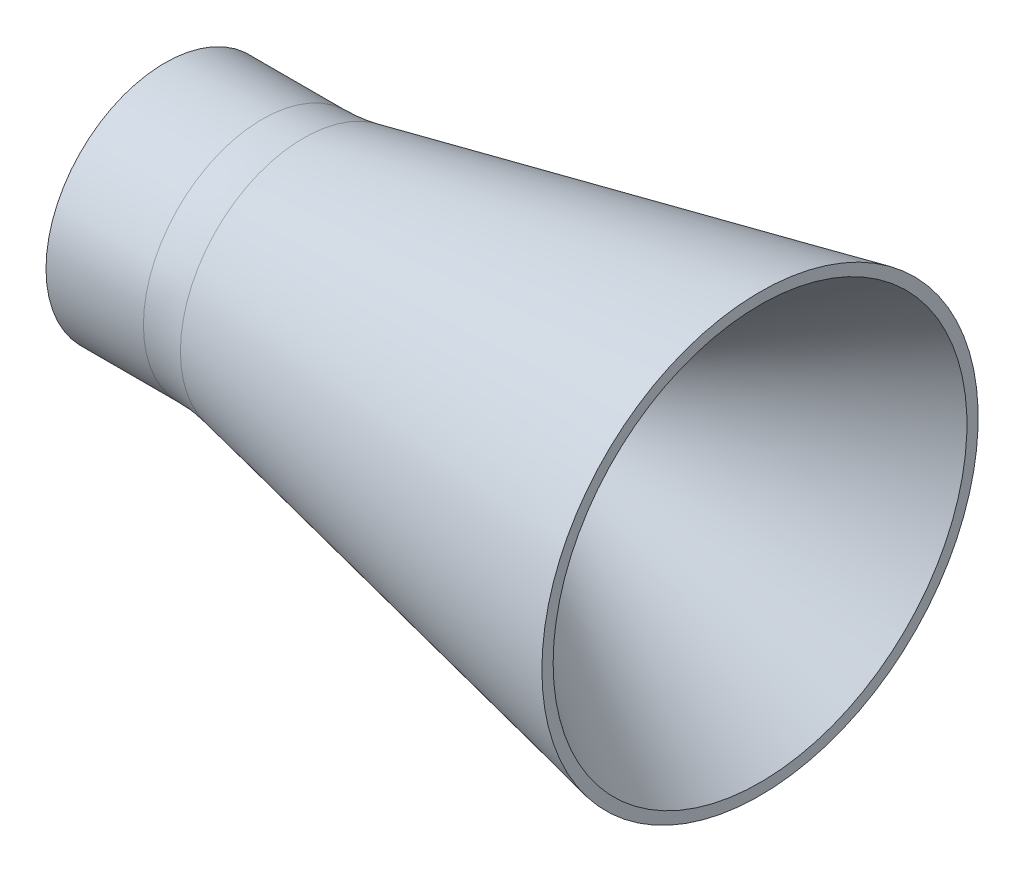
from build123d import *


with BuildPart() as part:
    # Sketch1 → Revolve2 (revolve)
    with BuildSketch(Plane.XY):
        with BuildLine():
            Line((45.639160326, 28.298601183), (95.74633283, 9.064259762))
            ThreePointArc((95.74633283, 9.064259762), (102.791629792, 7.077280519), (110.081050812, 6.407476822))
            Line((110.081050812, 6.407476822), (127.851823553, 6.407476822))
            ThreePointArc((127.851823553, 6.407476822), (139.546691742, 8.155286583), (150.219539692, 13.24597392))
            Line((150.219539692, 13.24597392), (246.802204076, 78.391803626))
            Line((246.802204076, 78.391803626), (246.802204076, 83.391803626))
            Line((246.802204076, 83.391803626), (43.876590917, 41.163939374))
            ThreePointArc((43.876590917, 41.163939374), (34.757151884, 39.749500606), (25.540810641, 39.276362798))
            Line((25.540810641, 39.276362798), (-17.770606993, 39.276362798))
            Line((-17.770606993, 39.276362798), (-17.770606993, 34.276362798))
            Line((-17.770606993, 34.276362798), (13.386044867, 34.276362798))
            ThreePointArc((13.386044867, 34.276362798), (29.787242162, 32.769304479), (45.639160326, 28.298601183))
        make_face()
    revolve(axis=Axis((-9.079018431, -13.592523178, 0), (1, 0, 0)))


solid = part.part
